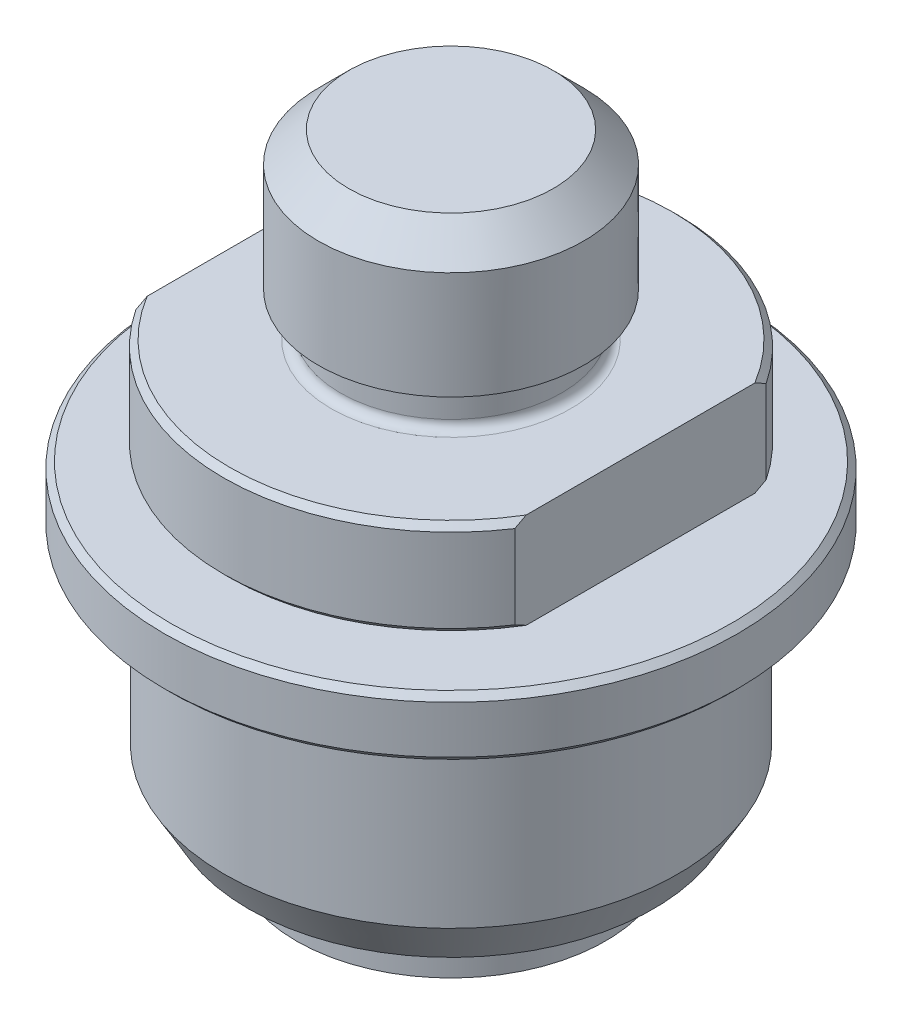
from build123d import *

# Parameters (mm, degrees)
CHAMFER1_SIZE      = 0.508
CHAMFER2_SIZE      = 2.54
CUT_EXTRUDE1_DEPTH = 38.1602
CHAMFER3_SIZE      = 0.508
SKETCH3_R          = 0.9652
REVOLVE3_ANGLE     = 315


with BuildPart() as part:
    # Sketch1 → Revolve1 (revolve)
    with BuildSketch(Plane.XY, mode=Mode.PRIVATE) as revolve1_sk:
        with BuildLine():
            Line((0, 15.24), (0, -21.6916))
            Line((0, -21.6916), (4.699, -21.6916))
            Line((4.699, -21.6916), (9.0424, -26.035))
            Line((9.0424, -26.035), (9.0424, -35.6362))
            ThreePointArc((9.0424, -35.6362), (9.488769265, -36.713830735), (10.5664, -37.1602))
            Line((10.5664, -37.1602), (12.954, -37.1602))
            Line((12.954, -37.1602), (12.954, -35.433))
            ThreePointArc((12.954, -35.433), (11.938, -34.417), (12.954, -33.401))
            Line((12.954, -33.401), (12.954, -8.001))
            Line((12.954, -8.001), (19.05, -8.001))
            Line((19.05, -8.001), (19.05, 0))
            Line((19.05, 0), (10.033, 0))
            ThreePointArc((10.033, 0), (9.494184633, 0.223184633), (9.271, 0.762))
            Line((9.271, 0.762), (9.271, 3.683))
            Line((9.271, 3.683), (11.1125, 3.683))
            Line((11.1125, 3.683), (11.1125, 15.24))
            Line((11.1125, 15.24), (0, 15.24))
        make_face()
    revolve(revolve1_sk.sketch.rotate(Axis((0, 15.24, 0), (0, 1, 0)), 90), axis=Axis((0, 15.24, 0), (0, 1, 0)))  # turned: the seam where the file's is

    # Chamfer1
    chamfer1_edges = [part.edges().sort_by_distance(p)[0] for p in [
        (0, -8.001, 19.05),
        (0, 0, 19.05),
    ]]
    chamfer(chamfer1_edges, length=CHAMFER1_SIZE)

    # Chamfer2
    chamfer2_edges = [part.edges().sort_by_distance(p)[0] for p in [
        (0, 15.24, 11.1125),
    ]]
    chamfer(chamfer2_edges, length=CHAMFER2_SIZE)

    # Sketch4 → Cut-Extrude1 (cut, through all)
    with BuildSketch(Plane(origin=(0, 0, 0), x_dir=(1, 0, 0), z_dir=(0, 1, 0))):
        with BuildLine():
            Line((-15.875, 10.530283709), (-15.875, -10.530283709))
            ThreePointArc((-15.875, -10.530283709), (-19.05, 0), (-15.875, 10.530283709))
        make_face()
        with BuildLine():
            Line((15.875, 10.530283709), (15.875, -10.530283709))
            ThreePointArc((15.875, -10.530283709), (19.05, 0), (15.875, 10.530283709))
        make_face()
    extrude(amount=-CUT_EXTRUDE1_DEPTH, mode=Mode.SUBTRACT)


with BuildPart() as body_2:
    # Sketch2 → Revolve2 (revolve)
    with BuildSketch(Plane.XY, mode=Mode.PRIVATE) as revolve2_sk:
        with BuildLine():
            Line((13.0048, -8.8392), (13.0048, -29.083))
            Line((13.0048, -29.083), (13.97, -29.083))
            ThreePointArc((13.97, -29.083), (14.68842049, -29.38057951), (14.986, -30.099))
            Line((14.986, -30.099), (14.986, -32.8422))
            Line((14.986, -32.8422), (16.946142443, -32.8422))
            Line((16.946142443, -32.8422), (18.9992, -29.2862))
            Line((18.9992, -29.2862), (18.9992, -14.605))
            ThreePointArc((18.9992, -14.605), (19.222384633, -14.066184633), (19.7612, -13.843))
            Line((19.7612, -13.843), (24.003, -13.843))
            Line((24.003, -13.843), (24.003, -8.8392))
            Line((24.003, -8.8392), (13.0048, -8.8392))
        make_face()
    revolve(revolve2_sk.sketch.rotate(Axis((0, 0, 0), (0, 1, 0)), 90), axis=Axis((0, 0, 0), (0, 1, 0)))  # turned: the seam where the file's is

    # Chamfer3
    chamfer3_edges = [body_2.edges().sort_by_distance(p)[0] for p in [
        (0, -8.8392, 24.003),
        (0, -13.843, 24.003),
    ]]
    chamfer(chamfer3_edges, length=CHAMFER3_SIZE)


with BuildPart() as body_3:
    # Sketch3 → Revolve3 (revolve)
    with BuildSketch(Plane.XY):
        with Locations((12.954, -34.417)):
            Circle(SKETCH3_R)
    revolve(axis=Axis((0, 0, 0), (0, -1, 0)), revolution_arc=REVOLVE3_ANGLE)


solid = Compound([part.part, body_2.part, body_3.part])
